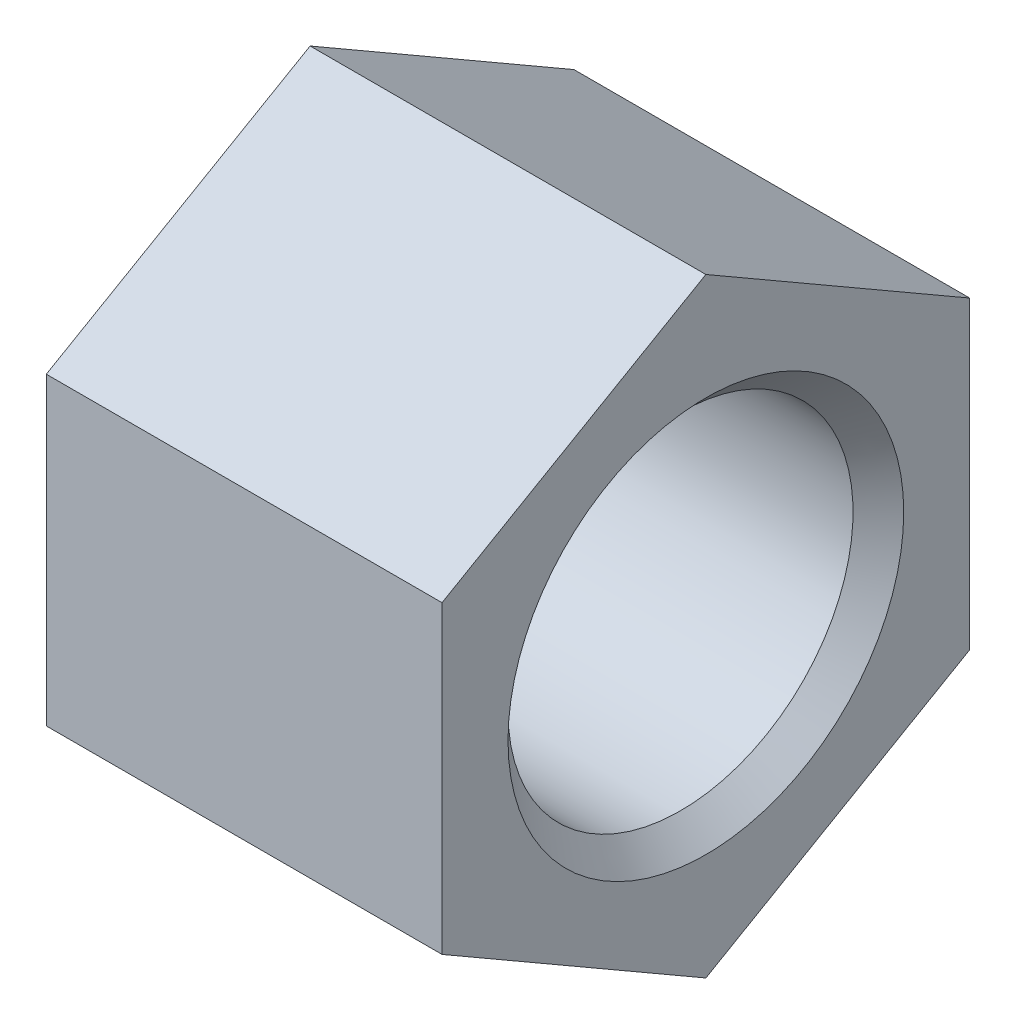
from build123d import *

# Parameters (mm, degrees)
CHAMFER_1_SIZE  = 1.921
SKETCH_2_R      = 19.5
EXTRUDE_1_DEPTH = 30


with BuildPart() as part:
    # Эскиз1 → Повернуть1 (revolve)
    with BuildSketch(Plane.XY):
        Polygon((0, 6.5), (5, 6.5), (5, 15), (10, 15), (10, 13.079), (30, 13.079), (30, 19.5), (0, 19.5), align=None)
    revolve(axis=Axis((0, 0, 0), (1, 0, 0)))

    # Фаска1
    chamfer_1_edges = [part.edges().sort_by_distance(p)[0] for p in [
        (30, -13.079, 0),
    ]]
    chamfer(chamfer_1_edges, length=CHAMFER_1_SIZE)

    # Эскиз2 → Бобышка-Вытянуть1 (add)
    with BuildSketch(Plane(origin=(30, 0, 0), x_dir=(0, 0, -1), z_dir=(1, 0, 0))):
        Polygon((0, 23.094010768), (-20, 11.547005384), (-20, -11.547005384), (0, -23.094010768), (20, -11.547005384), (20, 11.547005384), align=None)
        Circle(SKETCH_2_R, mode=Mode.SUBTRACT)
    extrude(amount=-EXTRUDE_1_DEPTH)


solid = part.part
